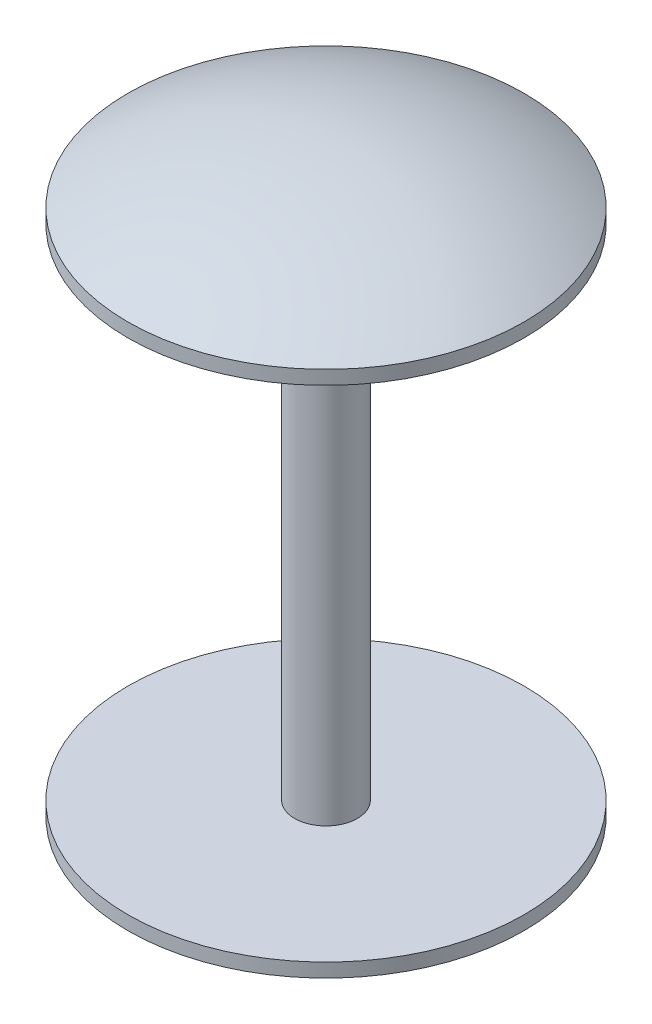
from build123d import *

# Parameters (mm, degrees)
SKETCH1_R           = 14.278677311
SKETCH1_R_2         = 2.261632511
BOSS_EXTRUDE1_DEPTH = 19
SKETCH1_3_R         = 14.278677311
SKETCH1_3_R_2       = 2.261632511
CUT_EXTRUDE1_DEPTH  = 18
DOME1_FACE_RADIUS   = 14.278677311
DOME1_HEIGHT        = 4
DOME2_FACE_RADIUS   = 14.278677311
DOME2_HEIGHT        = 4


with BuildPart() as part:
    # Sketch1 → Boss-Extrude1 (new, symmetric)
    with BuildSketch(Plane(origin=(0, 0, 0), x_dir=(1, 0, 0), z_dir=(0, 1, 0))):
        with Locations(Location((0, 0, 0), (0, 0, 270))):
            Circle(SKETCH1_R)
        Circle(SKETCH1_R_2, mode=Mode.SUBTRACT)
        Circle(SKETCH1_R_2)
    extrude(amount=BOSS_EXTRUDE1_DEPTH, both=True)

    # Sketch1_3 → Cut-Extrude1 (cut, symmetric)
    with BuildSketch(Plane(origin=(0, 0, 0), x_dir=(1, 0, 0), z_dir=(0, 1, 0))):
        with Locations(Location((0, 0, 0), (0, 0, 270))):
            Circle(SKETCH1_3_R)
        with Locations(Location((0, 0, 0), (0, 0, 270))):
            Circle(SKETCH1_3_R_2, mode=Mode.SUBTRACT)
    extrude(amount=CUT_EXTRUDE1_DEPTH, both=True, mode=Mode.SUBTRACT)

    # Dome1: a dome of height H over a round flat face of radius A is a cap of a sphere of radius (A * A + H * H) / (2 * H)
    dome1_r = (DOME1_FACE_RADIUS * DOME1_FACE_RADIUS + DOME1_HEIGHT * DOME1_HEIGHT) / (2 * DOME1_HEIGHT)
    dome1_base = Plane((0, -19, 0), z_dir=(0, -1, 0))
    with Locations(dome1_base.offset(DOME1_HEIGHT - dome1_r)):
        dome1_ball = Sphere(dome1_r, mode=Mode.PRIVATE)
    add(split(dome1_ball, bisect_by=dome1_base, keep=Keep.TOP, mode=Mode.PRIVATE))

    # Dome2: a dome of height H over a round flat face of radius A is a cap of a sphere of radius (A * A + H * H) / (2 * H)
    dome2_r = (DOME2_FACE_RADIUS * DOME2_FACE_RADIUS + DOME2_HEIGHT * DOME2_HEIGHT) / (2 * DOME2_HEIGHT)
    dome2_base = Plane((0, 19, 0), z_dir=(0, 1, 0))
    with Locations(dome2_base.offset(DOME2_HEIGHT - dome2_r)):
        dome2_ball = Sphere(dome2_r, mode=Mode.PRIVATE)
    add(split(dome2_ball, bisect_by=dome2_base, keep=Keep.TOP, mode=Mode.PRIVATE))


solid = part.part
